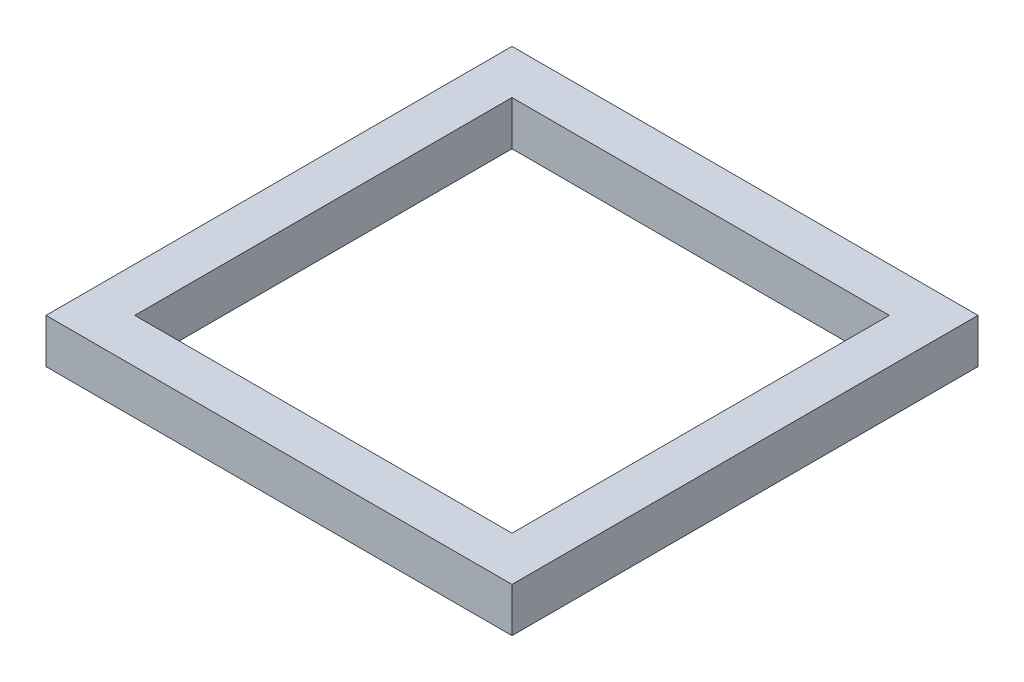
from build123d import *

# Parameters (mm, degrees)
SKETCH1_W           = 10.5
SKETCH1_H           = 10.5
BOSS_EXTRUDE1_DEPTH = 1
SKETCH2_W           = 8.5
SKETCH2_H           = 8.5
CUT_EXTRUDE1_DEPTH  = 2


with BuildPart() as part:
    # Sketch1 → Boss-Extrude1 (new body)
    with BuildSketch(Plane(origin=(0, 0, 0), x_dir=(1, 0, 0), z_dir=(0, 1, 0))):
        with Locations((5.25, 5.25)):
            Rectangle(SKETCH1_W, SKETCH1_H)
    extrude(amount=BOSS_EXTRUDE1_DEPTH)

    # Sketch2 → Cut-Extrude1 (cut, through all)
    with BuildSketch(Plane(origin=(0, 1, 0), x_dir=(1, 0, 0), z_dir=(0, 1, 0))):
        with Locations((5.25, 5.25)):
            Rectangle(SKETCH2_W, SKETCH2_H)
    extrude(amount=-CUT_EXTRUDE1_DEPTH, mode=Mode.SUBTRACT)


solid = part.part
